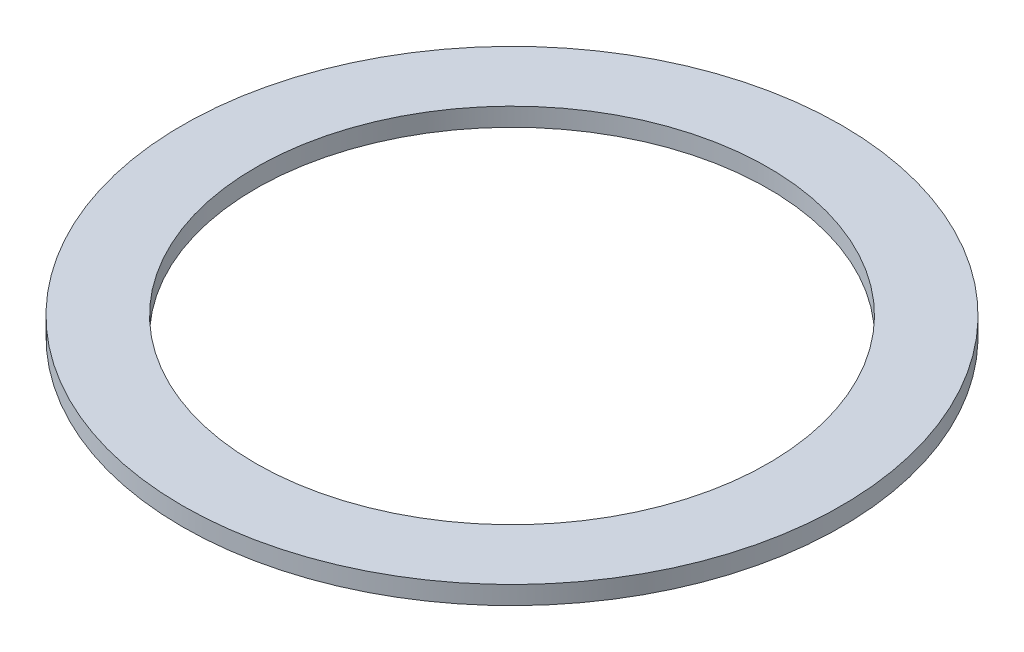
from build123d import *

# Parameters (mm, degrees)
SKETCH1_R           = 90
SKETCH1_R_2         = 70
BOSS_EXTRUDE1_DEPTH = 5


with BuildPart() as part:
    # Sketch1 → Boss-Extrude1 (new body)
    with BuildSketch(Plane(origin=(0, 0, 0), x_dir=(1, 0, 0), z_dir=(0, 1, 0))):
        Circle(SKETCH1_R)
        Circle(SKETCH1_R_2, mode=Mode.SUBTRACT)
    extrude(amount=BOSS_EXTRUDE1_DEPTH)


solid = part.part
